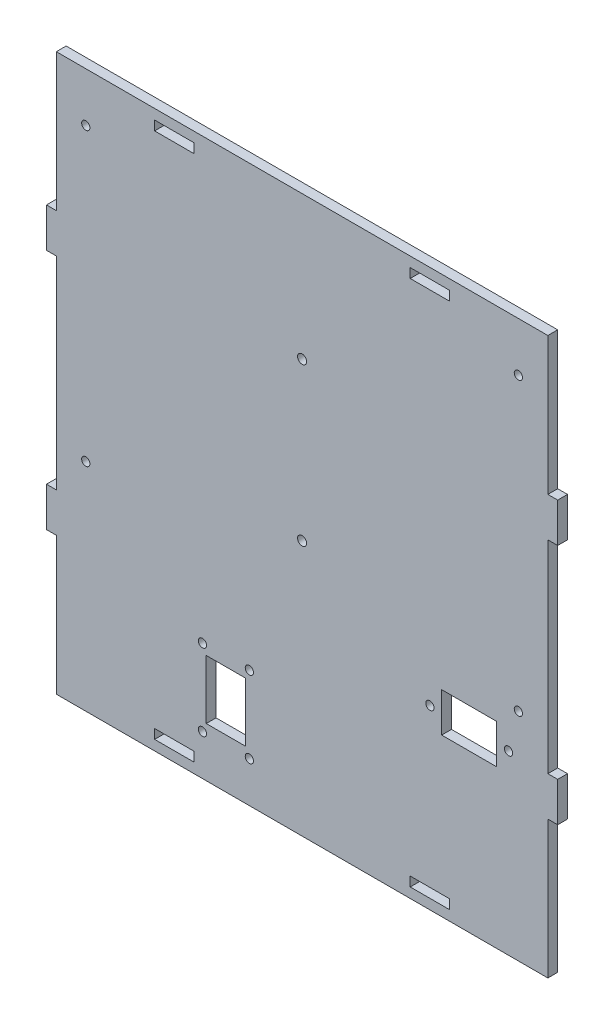
from build123d import *

# Parameters (mm, degrees)
SKETCH1_W           = 250
SKETCH1_H           = 283
SKETCH1_R           = 2.3
SKETCH1_W_2         = 20
SKETCH1_H_2         = 4.8
BOSS_EXTRUDE1_DEPTH = 5
SKETCH2_W           = 5
SKETCH2_H           = 20
BOSS_EXTRUDE2_DEPTH = 5
SKETCH3_R           = 2.1
SKETCH3_W           = 28
SKETCH3_H           = 20
CUT_EXTRUDE1_DEPTH  = 5
SKETCH4_W           = 20
SKETCH4_H           = 30
CUT_EXTRUDE2_DEPTH  = 5
SKETCH5_R           = 2.1
CUT_EXTRUDE3_DEPTH  = 6
SKETCH6_R           = 2.1
CUT_EXTRUDE4_DEPTH  = 5
SKETCH7_R           = 2.1
CUT_EXTRUDE5_DEPTH  = 5


with BuildPart() as part:
    # Sketch1 → Boss-Extrude1 (new body)
    with BuildSketch(Plane.XY):
        with Locations((125, 136.5)):
            Rectangle(SKETCH1_W, SKETCH1_H)
        with Locations((125, 125.1)):
            Circle(SKETCH1_R, mode=Mode.SUBTRACT)
        with Locations((125, 205.1)):
            Circle(SKETCH1_R, mode=Mode.SUBTRACT)
        with Locations((60, 2.5)):
            Rectangle(SKETCH1_W_2, SKETCH1_H_2, mode=Mode.SUBTRACT)
        with Locations((190, 2.5)):
            Rectangle(SKETCH1_W_2, SKETCH1_H_2, mode=Mode.SUBTRACT)
        with Locations((190, 270.5)):
            Rectangle(SKETCH1_W_2, SKETCH1_H_2, mode=Mode.SUBTRACT)
        with Locations((60, 270.5)):
            Rectangle(SKETCH1_W_2, SKETCH1_H_2, mode=Mode.SUBTRACT)
    extrude(amount=BOSS_EXTRUDE1_DEPTH)

    # Sketch2 → Boss-Extrude2 (add)
    with BuildSketch(Plane.XY.offset(5)):
        with Locations((-2.5, 198)):
            Rectangle(SKETCH2_W, SKETCH2_H)
        with Locations((-2.5, 75)):
            Rectangle(SKETCH2_W, SKETCH2_H)
        with Locations((252.5, 198)):
            Rectangle(SKETCH2_W, SKETCH2_H)
        with Locations((252.5, 75)):
            Rectangle(SKETCH2_W, SKETCH2_H)
    extrude(amount=-BOSS_EXTRUDE2_DEPTH)

    # Sketch3 → Cut-Extrude1 (cut)
    with BuildSketch(Plane.XY.offset(5)):
        with Locations((190, 85)):
            Circle(SKETCH3_R)
        with Locations((230, 85)):
            Circle(SKETCH3_R)
        with Locations((210, 85)):
            Rectangle(SKETCH3_W, SKETCH3_H)
    extrude(amount=-CUT_EXTRUDE1_DEPTH, mode=Mode.SUBTRACT)

    # Sketch4 → Cut-Extrude2 (cut)
    with BuildSketch(Plane.XY.offset(5)):
        with Locations((86.25, 35.2)):
            Rectangle(SKETCH4_W, SKETCH4_H)
    extrude(amount=-CUT_EXTRUDE2_DEPTH, mode=Mode.SUBTRACT)

    # Sketch5 → Cut-Extrude3 (cut, through all)
    with BuildSketch(Plane.XY.offset(5)):
        with Locations((98.18627451, 15.72)):
            Circle(SKETCH5_R)
        with Locations((74.31372549, 15.72)):
            Circle(SKETCH5_R)
        with Locations((74.31372549, 54.68)):
            Circle(SKETCH5_R)
        with Locations((98.18627451, 54.68)):
            Circle(SKETCH5_R)
    extrude(amount=-CUT_EXTRUDE3_DEPTH, mode=Mode.SUBTRACT)

    # Sketch6 → Cut-Extrude4 (cut)
    with BuildSketch(Plane.XY.offset(5)):
        with Locations((235, 253)):
            Circle(SKETCH6_R)
        with Locations((15, 253)):
            Circle(SKETCH6_R)
    extrude(amount=-CUT_EXTRUDE4_DEPTH, mode=Mode.SUBTRACT)

    # Sketch7 → Cut-Extrude5 (cut)
    with BuildSketch(Plane.XY.offset(5)):
        with Locations((15, 105)):
            Circle(SKETCH7_R)
        with Locations((235, 105)):
            Circle(SKETCH7_R)
    extrude(amount=-CUT_EXTRUDE5_DEPTH, mode=Mode.SUBTRACT)


solid = part.part
